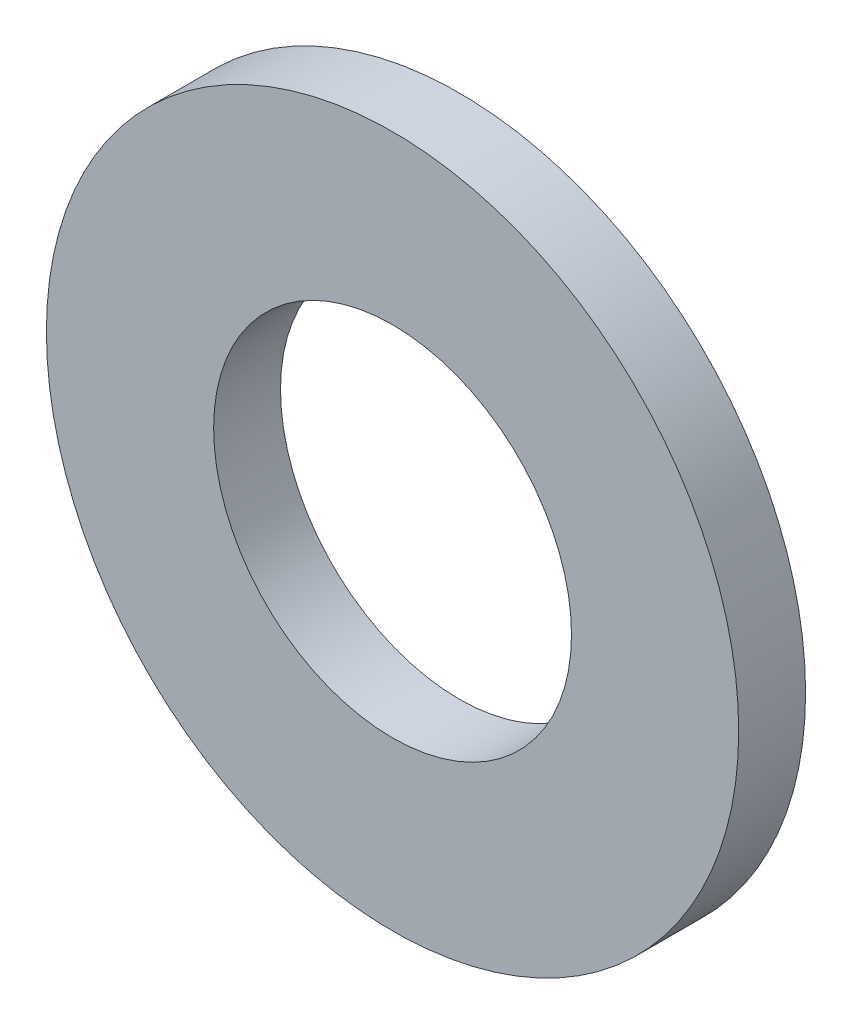
from build123d import *

# Parameters (mm, degrees)
SKETCH1_R           = 10.35
SKETCH1_R_2         = 5.35
BOSS_EXTRUDE1_DEPTH = 2


with BuildPart() as part:
    # Sketch1 → Boss-Extrude1 (new body)
    with BuildSketch(Plane.XY):
        Circle(SKETCH1_R)
        Circle(SKETCH1_R_2, mode=Mode.SUBTRACT)
    extrude(amount=BOSS_EXTRUDE1_DEPTH)


solid = part.part
